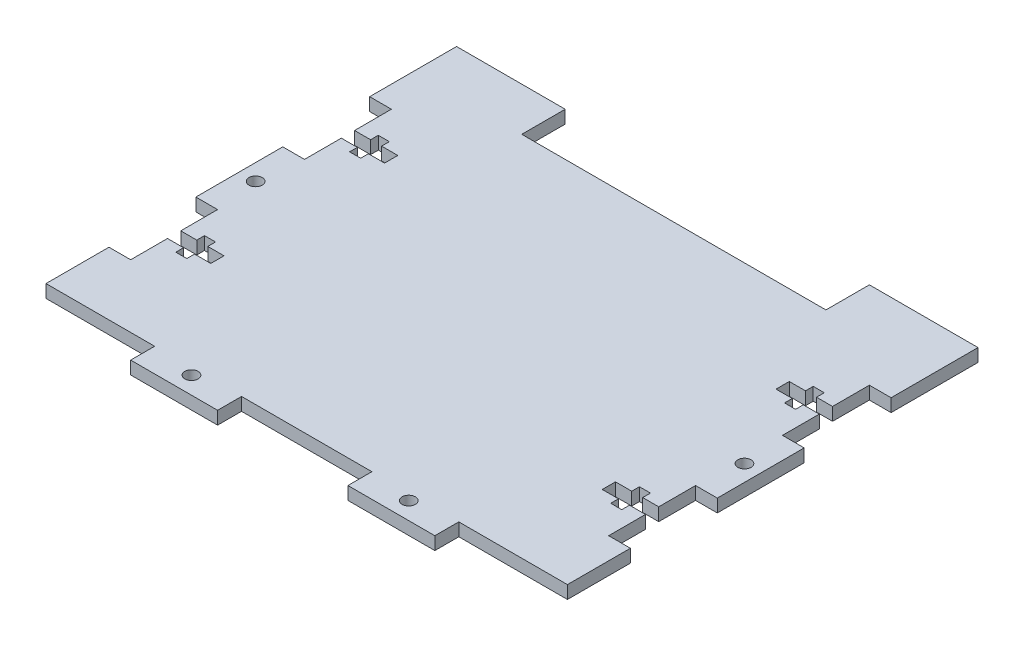
from build123d import *

# Parameters (mm, degrees)
SKETCH1_W                 = 120
SKETCH1_H                 = 100
BOSS_EXTRUDE1_DEPTH       = 2.9718
SKETCH2_W                 = 70
SKETCH2_H                 = 20
CUT_EXTRUDE1_DEPTH        = 3.9718
SKETCH3_W                 = 29.908
SKETCH3_H                 = 3.048
CUT_EXTRUDE2_DEPTH        = 3.9718
SKETCH4_W                 = 10
SKETCH4_H                 = 20
SKETCH4_W_2               = 2.54
SKETCH4_H_2               = 6.604
CUT_EXTRUDE3_DEPTH        = 2.9718
MIRROR2_COPY_1_SKETCH_W   = 29.908
MIRROR2_COPY_1_SKETCH_H   = 3.048
MIRROR2_COPY_1_DEPTH      = 3.9718
MIRROR2_COPY_2_SKETCH_W   = 10
MIRROR2_COPY_2_SKETCH_H   = 20
MIRROR2_COPY_2_SKETCH_W_2 = 2.54
MIRROR2_COPY_2_SKETCH_H_2 = 6.604
MIRROR2_COPY_2_DEPTH      = 2.9718
SKETCH6_W                 = 50
SKETCH6_H                 = 11.0236
CUT_EXTRUDE4_DEPTH        = 3.9718
SKETCH7_W                 = 30
SKETCH7_H                 = 11.0236
CUT_EXTRUDE6_DEPTH        = 3.9718
SKETCH8_R                 = 1.524
CUT_EXTRUDE7_DEPTH        = 3.9718
SKETCH11_R                = 1.524
CUT_EXTRUDE8_DEPTH        = 3.9718


with BuildPart() as part:
    # Sketch1 → Boss-Extrude1 (new body)
    with BuildSketch(Plane(origin=(0, 0, 0), x_dir=(1, 0, 0), z_dir=(0, 1, 0))):
        Rectangle(SKETCH1_W, SKETCH1_H)
    extrude(amount=BOSS_EXTRUDE1_DEPTH)

    # Sketch2 → Cut-Extrude1 (cut, through all)
    with BuildSketch(Plane(origin=(0, 2.9718, 0), x_dir=(1, 0, 0), z_dir=(0, 1, 0))):
        with Locations((0, 50)):
            Rectangle(SKETCH2_W, SKETCH2_H)
    extrude(amount=-CUT_EXTRUDE1_DEPTH, mode=Mode.SUBTRACT)

    # Sketch3 → Cut-Extrude2 (cut, through all)
    with BuildSketch(Plane(origin=(0, 2.9718, 0), x_dir=(1, 0, 0), z_dir=(0, 1, 0))):
        with Locations((-60, 20)):
            Rectangle(SKETCH3_W, SKETCH3_H)
    cut_extrude2 = extrude(amount=-CUT_EXTRUDE2_DEPTH, mode=Mode.SUBTRACT)

    # Sketch4 → Cut-Extrude3 (cut)
    with BuildSketch(Plane(origin=(0, 2.9718, 0), x_dir=(1, 0, 0), z_dir=(0, 1, 0))):
        with Locations((-60, 20)):
            Rectangle(SKETCH4_W, SKETCH4_H)
        with Locations((-50.046, 20)):
            Rectangle(SKETCH4_W_2, SKETCH4_H_2)
    cut_extrude3 = extrude(amount=-CUT_EXTRUDE3_DEPTH, mode=Mode.SUBTRACT)

    # Mirror1: Cut-Extrude2, Cut-Extrude3 across plane
    add(cut_extrude2.mirror(Plane.XY), mode=Mode.SUBTRACT)
    add(cut_extrude3.mirror(Plane.XY), mode=Mode.SUBTRACT)

    # Mirror2: Cut-Extrude3, Cut-Extrude2 across plane
    add(cut_extrude3.mirror(Plane(origin=(0, 0, 0), x_dir=(0, 0, 1), z_dir=(1, 0, 0))), mode=Mode.SUBTRACT)
    add(cut_extrude2.mirror(Plane(origin=(0, 0, 0), x_dir=(0, 0, 1), z_dir=(1, 0, 0))), mode=Mode.SUBTRACT)

    # Mirror2 copy 1 sketch → Mirror2 copy 1 (cut, through all)
    with BuildSketch(Plane(origin=(0, 2.9718, 0), x_dir=(-1, 0, 0), z_dir=(0, 1, 0))):
        with Locations((-60, 20)):
            Rectangle(MIRROR2_COPY_1_SKETCH_W, MIRROR2_COPY_1_SKETCH_H)
    extrude(amount=-MIRROR2_COPY_1_DEPTH, mode=Mode.SUBTRACT)

    # Mirror2 copy 2 sketch → Mirror2 copy 2 (cut)
    with BuildSketch(Plane(origin=(0, 2.9718, 0), x_dir=(-1, 0, 0), z_dir=(0, 1, 0))):
        with Locations((-60, 20)):
            Rectangle(MIRROR2_COPY_2_SKETCH_W, MIRROR2_COPY_2_SKETCH_H)
        with Locations((-50.046, 20)):
            Rectangle(MIRROR2_COPY_2_SKETCH_W_2, MIRROR2_COPY_2_SKETCH_H_2)
    extrude(amount=-MIRROR2_COPY_2_DEPTH, mode=Mode.SUBTRACT)

    # Sketch6 → Cut-Extrude4 (cut, through all)
    with BuildSketch(Plane(origin=(0, 2.9718, 0), x_dir=(1, 0, 0), z_dir=(0, 1, 0))):
        with Locations((-60, -50)):
            Rectangle(SKETCH6_W, SKETCH6_H)
        with Locations((60, -50)):
            Rectangle(SKETCH6_W, SKETCH6_H)
    extrude(amount=-CUT_EXTRUDE4_DEPTH, mode=Mode.SUBTRACT)

    # Sketch7 → Cut-Extrude6 (cut, through all)
    with BuildSketch(Plane(origin=(0, 2.9718, 0), x_dir=(1, 0, 0), z_dir=(0, 1, 0))):
        with Locations((0, -50)):
            Rectangle(SKETCH7_W, SKETCH7_H)
    extrude(amount=-CUT_EXTRUDE6_DEPTH, mode=Mode.SUBTRACT)

    # Sketch8 → Cut-Extrude7 (cut, through all)
    with BuildSketch(Plane(origin=(0, 2.9718, 0), x_dir=(1, 0, 0), z_dir=(0, 1, 0))):
        with Locations((-25, -46.0122)):
            Circle(SKETCH8_R)
        with Locations((25, -46.0122)):
            Circle(SKETCH8_R)
    extrude(amount=-CUT_EXTRUDE7_DEPTH, mode=Mode.SUBTRACT)

    # Sketch11 → Cut-Extrude8 (cut, through all)
    with BuildSketch(Plane(origin=(0, 2.9718, 0), x_dir=(1, 0, 0), z_dir=(0, 1, 0))):
        with Locations((-56.2474, 0)):
            Circle(SKETCH11_R)
        with Locations((56.2474, 0)):
            Circle(SKETCH11_R)
    extrude(amount=-CUT_EXTRUDE8_DEPTH, mode=Mode.SUBTRACT)


solid = part.part
